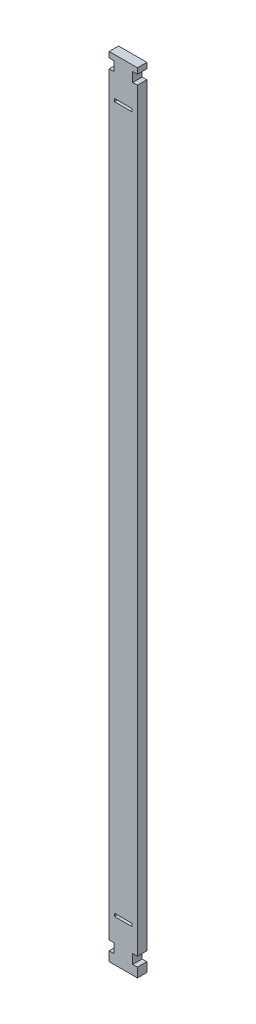
from build123d import *

# Parameters (mm, degrees)
SKETCH_1_W          = 15
SKETCH_1_H          = 450
EXTRUDE_1_DEPTH     = 5
CUT_EXTRUDE_1_REACH = 7
SKETCH_2_W          = 2.5
SKETCH_2_H          = 5
SKETCH_2_W_2        = 15
SKETCH_2_H_2        = 32
CUT_EXTRUDE_2_REACH = 7
SKETCH_3_W          = 9.5
SKETCH_3_H          = 1.5


with BuildPart() as part:
    # 草图1 → 凸台-拉伸1 (new body)
    with BuildSketch(Plane.XY):
        Rectangle(SKETCH_1_W, SKETCH_1_H)
    extrude(amount=EXTRUDE_1_DEPTH)

    # 草图2 → 切除-拉伸1 (cut, up to next)
    with BuildSketch(Plane.XY.offset(5), mode=Mode.PRIVATE) as cut_extrude_1_sk1:
        with Locations((-6.25, -217.5)):
            Rectangle(SKETCH_2_W, SKETCH_2_H)
    cut_extrude_1_tool1 = extrude(cut_extrude_1_sk1.sketch, amount=-CUT_EXTRUDE_1_REACH, mode=Mode.PRIVATE) & part.part
    add(cut_extrude_1_tool1.solids().sort_by_distance((-6.25, -217.5, 5))[0], mode=Mode.SUBTRACT)
    # 草图2 → 切除-拉伸1 (cut, up to next)
    with BuildSketch(Plane.XY.offset(5), mode=Mode.PRIVATE) as cut_extrude_1_sk2:
        with Locations((6.25, -217.5)):
            Rectangle(SKETCH_2_W, SKETCH_2_H)
    cut_extrude_1_tool2 = extrude(cut_extrude_1_sk2.sketch, amount=-CUT_EXTRUDE_1_REACH, mode=Mode.PRIVATE) & part.part
    add(cut_extrude_1_tool2.solids().sort_by_distance((6.25, -217.5, 5))[0], mode=Mode.SUBTRACT)
    # 草图2 → 切除-拉伸1 (cut, up to next)
    with BuildSketch(Plane.XY.offset(5), mode=Mode.PRIVATE) as cut_extrude_1_sk3:
        with Locations((-6.25, 187.5)):
            Rectangle(SKETCH_2_W, SKETCH_2_H)
    cut_extrude_1_tool3 = extrude(cut_extrude_1_sk3.sketch, amount=-CUT_EXTRUDE_1_REACH, mode=Mode.PRIVATE) & part.part
    add(cut_extrude_1_tool3.solids().sort_by_distance((-6.25, 187.5, 5))[0], mode=Mode.SUBTRACT)
    # 草图2 → 切除-拉伸1 (cut, up to next)
    with BuildSketch(Plane.XY.offset(5), mode=Mode.PRIVATE) as cut_extrude_1_sk4:
        with Locations((6.25, 187.5)):
            Rectangle(SKETCH_2_W, SKETCH_2_H)
    cut_extrude_1_tool4 = extrude(cut_extrude_1_sk4.sketch, amount=-CUT_EXTRUDE_1_REACH, mode=Mode.PRIVATE) & part.part
    add(cut_extrude_1_tool4.solids().sort_by_distance((6.25, 187.5, 5))[0], mode=Mode.SUBTRACT)
    # 草图2 → 切除-拉伸1 (cut, up to next)
    with BuildSketch(Plane.XY.offset(5), mode=Mode.PRIVATE) as cut_extrude_1_sk5:
        with Locations((0, 209)):
            Rectangle(SKETCH_2_W_2, SKETCH_2_H_2)
    cut_extrude_1_tool5 = extrude(cut_extrude_1_sk5.sketch, amount=-CUT_EXTRUDE_1_REACH, mode=Mode.PRIVATE) & part.part
    add(cut_extrude_1_tool5.solids().sort_by_distance((0, 209, 5))[0], mode=Mode.SUBTRACT)

    # 草图3 → 切除-拉伸2 (cut, up to next)
    with BuildSketch(Plane.XY.offset(5), mode=Mode.PRIVATE) as cut_extrude_2_sk1:
        with Locations((0, -202.085)):
            Rectangle(SKETCH_3_W, SKETCH_3_H)
    cut_extrude_2_tool1 = extrude(cut_extrude_2_sk1.sketch, amount=-CUT_EXTRUDE_2_REACH, mode=Mode.PRIVATE) & part.part
    add(cut_extrude_2_tool1.solids().sort_by_distance((0, -202.085, 5))[0], mode=Mode.SUBTRACT)
    # 草图3 → 切除-拉伸2 (cut, up to next)
    with BuildSketch(Plane.XY.offset(5), mode=Mode.PRIVATE) as cut_extrude_2_sk2:
        with Locations((0, 172.085)):
            Rectangle(SKETCH_3_W, SKETCH_3_H)
    cut_extrude_2_tool2 = extrude(cut_extrude_2_sk2.sketch, amount=-CUT_EXTRUDE_2_REACH, mode=Mode.PRIVATE) & part.part
    add(cut_extrude_2_tool2.solids().sort_by_distance((0, 172.085, 5))[0], mode=Mode.SUBTRACT)


solid = part.part
